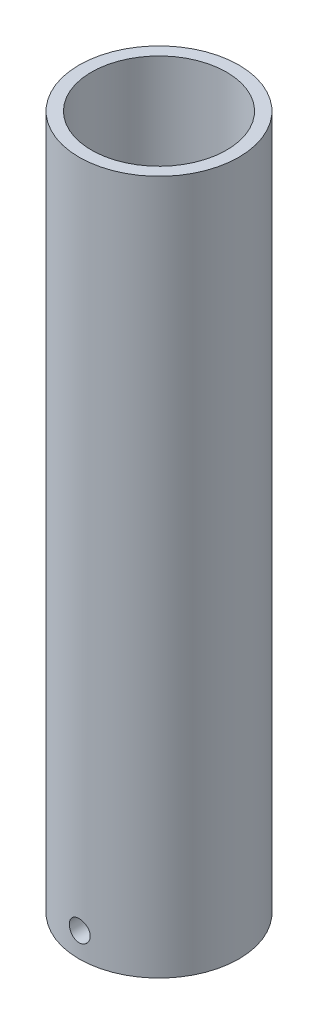
from build123d import *

# Parameters (mm, degrees)
SKETCH7_R          = 13
SKETCH7_R_2        = 8
CUT_EXTRUDE3_DEPTH = 3
SKETCH6_R          = 1.7
CUT_EXTRUDE2_DEPTH = 8


with BuildPart() as part:
    # Sketch1 → Revolve1 (revolve)
    with BuildSketch(Plane.XY):
        Polygon((-0.2, 0), (-0.2, 8), (-1.6, 8.841204867), (-1.6, 11), (-3.25, 11.991420021), (-3.25, 20.948493917), (-5, 22), (-5, 29), (-11, 32.605163714), (-11, 116), (-13, 116), (-13, 0), align=None)
    revolve(axis=Axis((0, 0, 0), (0, 1, 0)))

    # Sketch7 → Cut-Extrude3 (cut)
    with BuildSketch(Plane.XZ):
        Circle(SKETCH7_R)
        Circle(SKETCH7_R_2, mode=Mode.SUBTRACT)
    extrude(amount=-CUT_EXTRUDE3_DEPTH, mode=Mode.SUBTRACT)

    # Sketch6 → Cut-Extrude2 (cut)
    with BuildSketch(Plane.XY.offset(13)):
        with Locations((0, 7)):
            Circle(SKETCH6_R)
    extrude(amount=-CUT_EXTRUDE2_DEPTH, mode=Mode.SUBTRACT)


solid = part.part
